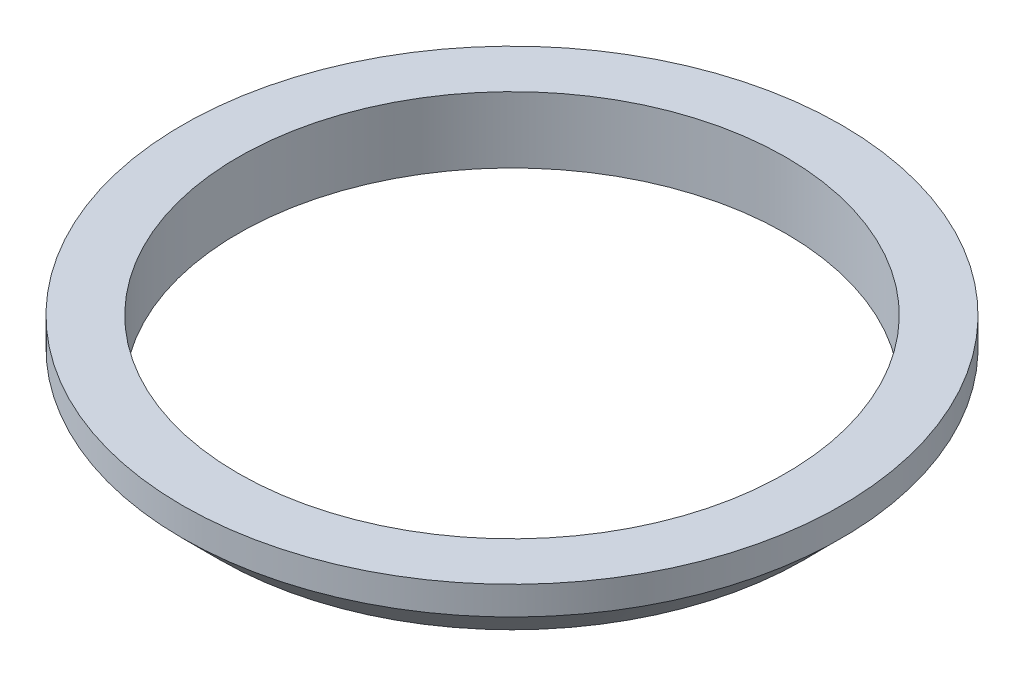
from build123d import *

# Parameters (mm, degrees)
ESQUISSE1_R        = 34.9
ESQUISSE1_R_2      = 29
BOSS_EXTRU_1_DEPTH = 7
CHANFREIN1_SIZE    = 4


with BuildPart() as part:
    # Esquisse1 → Boss.-Extru.1 (new body)
    with BuildSketch(Plane(origin=(0, 0, 0), x_dir=(1, 0, 0), z_dir=(0, 1, 0))):
        with Locations(Location((0, 0, 0), (0, 0, 270))):  # turned: the seam where the file's is
            Circle(ESQUISSE1_R)
        with Locations(Location((0, 0, 0), (0, 0, 270))):  # turned: the seam where the file's is
            Circle(ESQUISSE1_R_2, mode=Mode.SUBTRACT)
    extrude(amount=BOSS_EXTRU_1_DEPTH)

    # Chanfrein1
    chanfrein1_edges = [part.edges().sort_by_distance(p)[0] for p in [
        (0, 0, -34.9),
    ]]
    chamfer(chanfrein1_edges, length=CHANFREIN1_SIZE)


solid = part.part
